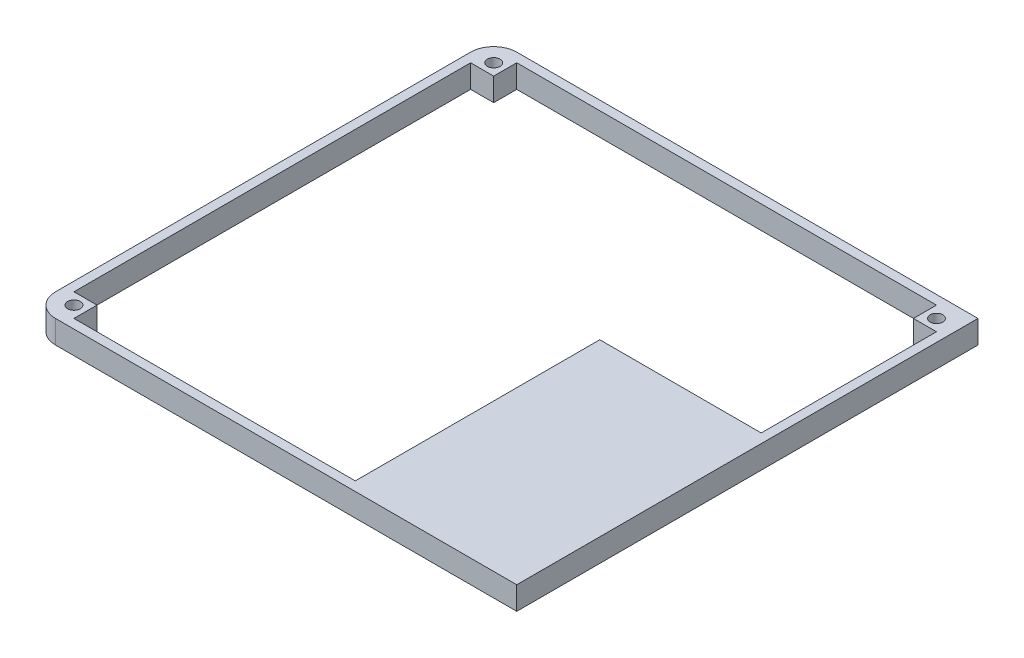
from build123d import *

# Parameters (mm, degrees)
SKETCH1_W                = 210
SKETCH1_H                = 200
SKETCH1_W_2              = 202
SKETCH1_H_2              = 192
BOSS_EXTRUDE1_DEPTH      = 10
SKETCH2_W                = 70
SKETCH2_H                = 106
BOSS_EXTRUDE2_DEPTH      = 10
SKETCH3_W                = 66
SKETCH3_H                = 102
CUT_EXTRUDE1_DEPTH       = 5
SKETCH4_W                = 10
SKETCH4_H                = 10
SKETCH4_R                = 2.75
BOSS_EXTRUDE3_DEPTH      = 10
FILLET1_R                = 10
BOSS_EXTRUDE4_DEPTH      = 5
BOSS_EXTRUDE4_DEPTH_BACK = 5


with BuildPart() as part:
    # Sketch1 → Boss-Extrude1 (new body)
    with BuildSketch(Plane(origin=(0, 0, 0), x_dir=(1, 0, 0), z_dir=(0, 1, 0))):
        with Locations((105, 100)):
            Rectangle(SKETCH1_W, SKETCH1_H)
        with Locations((105, 100)):
            Rectangle(SKETCH1_W_2, SKETCH1_H_2, mode=Mode.SUBTRACT)
    extrude(amount=-BOSS_EXTRUDE1_DEPTH)

    # Sketch2 → Boss-Extrude2 (add)
    with BuildSketch(Plane.XZ.offset(10)):
        with Locations((175, -53)):
            Rectangle(SKETCH2_W, SKETCH2_H)
    extrude(amount=-BOSS_EXTRUDE2_DEPTH)

    # Sketch3 → Cut-Extrude1 (cut)
    with BuildSketch(Plane.XZ.offset(10)):
        with Locations((173, -55)):
            Rectangle(SKETCH3_W, SKETCH3_H)
    extrude(amount=-CUT_EXTRUDE1_DEPTH, mode=Mode.SUBTRACT)

    # Sketch4 → Boss-Extrude3 (add)
    # profile 1 of 3: a face of its own
    with BuildSketch(Plane.XZ.offset(10)):
        with Locations((9, -9)):
            Rectangle(SKETCH4_W, SKETCH4_H)
        with Locations((9, -9)):
            Circle(SKETCH4_R, mode=Mode.SUBTRACT)
    # profile 2 of 3: a face of its own
    with BuildSketch(Plane.XZ.offset(10)):
        with Locations((9, -191)):
            Rectangle(SKETCH4_W, SKETCH4_H)
        with Locations((9, -191)):
            Circle(SKETCH4_R, mode=Mode.SUBTRACT)
    # profile 3 of 3: a face of its own
    with BuildSketch(Plane.XZ.offset(10)):
        with Locations((201, -191)):
            Rectangle(SKETCH4_W, SKETCH4_H)
        with Locations((201, -191)):
            Circle(SKETCH4_R, mode=Mode.SUBTRACT)
    extrude(amount=-BOSS_EXTRUDE3_DEPTH)

    # Fillet1
    fillet1_edges = [part.edges().sort_by_distance(p)[0] for p in [
        (0, -5, 0),
        (0, -5, -200),
    ]]
    fillet(fillet1_edges, radius=FILLET1_R)

    # Sketch5 → Boss-Extrude4 (add, two sides: drawn at the far end of the back side and taken through both)
    with BuildSketch(Plane.XZ.offset(5).offset(-BOSS_EXTRUDE4_DEPTH_BACK)):
        Polygon((206, -110), (206, -106), (140, -106), (140, -4), (136, -4), (136, -110), align=None)
    extrude(amount=BOSS_EXTRUDE4_DEPTH + BOSS_EXTRUDE4_DEPTH_BACK)


solid = part.part
